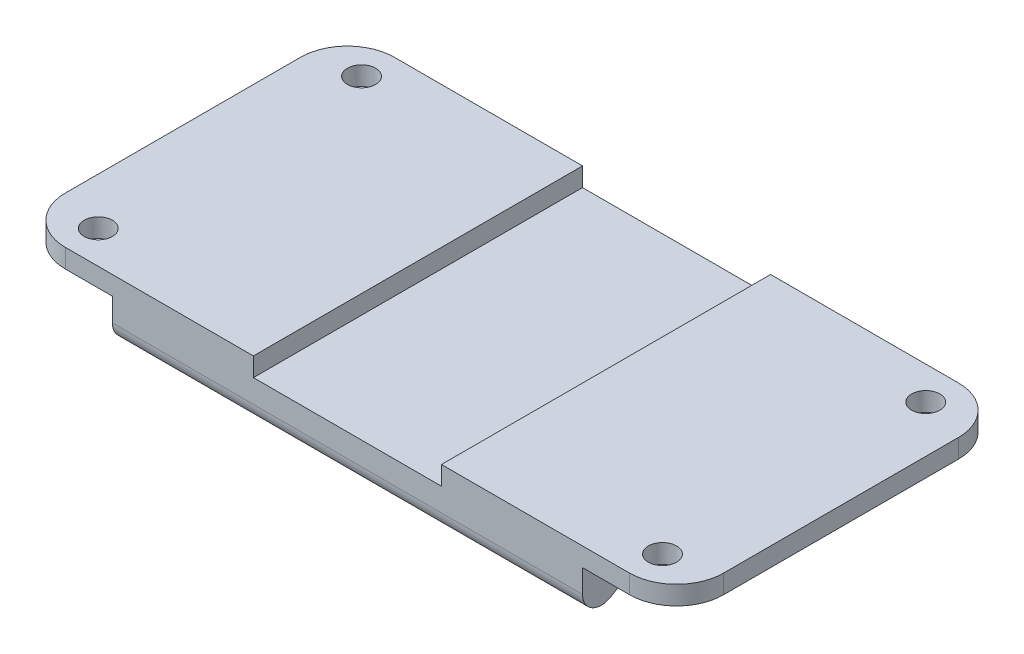
from build123d import *

# Parameters (mm, degrees)
SKETCH1_W               = 50
SKETCH1_H               = 35
BOSS_EXTRUDE1_DEPTH     = 8
CUT_EXTRUDE1_DEPTH      = 1
CUT_EXTRUDE1_DEPTH_BACK = 51
FILLET1_R               = 2
SKETCH5_W               = 35
SKETCH5_H               = 2
BOSS_EXTRUDE2_DEPTH     = 10
SKETCH6_R               = 1.5
CUT_EXTRUDE2_DEPTH      = 10
SKETCH3_W               = 10
SKETCH3_H               = 2
CUT_EXTRUDE3_DEPTH      = 36
FILLET3_R               = 5


with BuildPart() as part:
    # Sketch1 → Boss-Extrude1 (new body)
    with BuildSketch(Plane(origin=(0, 0, 0), x_dir=(1, 0, 0), z_dir=(0, 1, 0))):
        Rectangle(SKETCH1_W, SKETCH1_H)
    extrude(amount=-BOSS_EXTRUDE1_DEPTH)

    # Sketch2 → Cut-Extrude1 (cut, two sides)
    with BuildSketch(Plane(origin=(25, 0, 0), x_dir=(0, 0, -1), z_dir=(1, 0, 0))) as cut_extrude1_sk:
        Polygon((-12.5, -5), (-17.5, -8), (0, -8), (0, -5), align=None)
        Polygon((0, -5), (0, -8), (17.5, -8), (12.5, -5), align=None)
    extrude(amount=CUT_EXTRUDE1_DEPTH, mode=Mode.SUBTRACT)
    extrude(cut_extrude1_sk.sketch, amount=-CUT_EXTRUDE1_DEPTH_BACK, mode=Mode.SUBTRACT)

    # Fillet1
    fillet1_edges = [part.edges().sort_by_distance(p)[0] for p in [
        (0, -8, -17.5),
        (0, -5, 12.5),
        (0, -5, -12.5),
        (0, -8, 17.5),
    ]]
    fillet(fillet1_edges, radius=FILLET1_R)

    # Sketch5 → Boss-Extrude2 (add)
    with BuildSketch(Plane.ZY.offset(25)):
        with Locations((0, -1)):
            Rectangle(SKETCH5_W, SKETCH5_H)
    boss_extrude2 = extrude(amount=BOSS_EXTRUDE2_DEPTH)

    # Mirror1: Boss-Extrude2 across plane
    add(boss_extrude2.mirror(Plane(origin=(0, 0, 0), x_dir=(0, 0, 1), z_dir=(1, 0, 0))))

    # Sketch6 → Cut-Extrude2 (cut)
    with BuildSketch(Plane(origin=(0, 0, 0), x_dir=(1, 0, 0), z_dir=(0, 1, 0))):
        with Locations((-30, 14)):
            Circle(SKETCH6_R)
        with Locations((-30, -14)):
            Circle(SKETCH6_R)
        with Locations((30, -14)):
            Circle(SKETCH6_R)
        with Locations((30, 14)):
            Circle(SKETCH6_R)
    extrude(amount=-CUT_EXTRUDE2_DEPTH, mode=Mode.SUBTRACT)

    # Sketch3 → Cut-Extrude3 (cut, through all)
    with BuildSketch(Plane.XY.offset(17.5)):
        with Locations((5, -1)):
            Rectangle(SKETCH3_W, SKETCH3_H)
        with Locations((-5, -1)):
            Rectangle(SKETCH3_W, SKETCH3_H)
    extrude(amount=-CUT_EXTRUDE3_DEPTH, mode=Mode.SUBTRACT)

    # Fillet3
    fillet3_edges = [part.edges().sort_by_distance(p)[0] for p in [
        (-35, -1, -17.5),
        (-35, -1, 17.5),
        (35, -1, -17.5),
        (35, -1, 17.5),
    ]]
    fillet(fillet3_edges, radius=FILLET3_R)


solid = part.part
